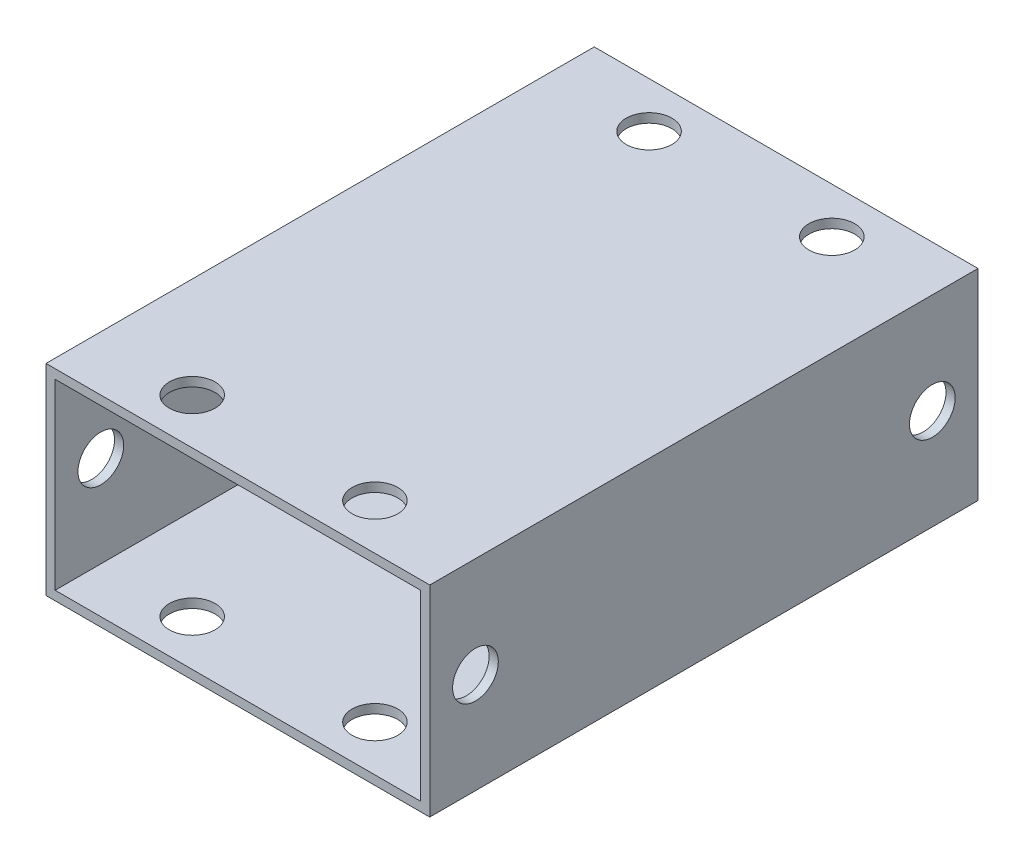
from build123d import *

# Parameters (mm, degrees)
BOSS_EXTRUDE1_DEPTH     = 60
SKETCH2_R               = 2.5
CUT_EXTRUDE1_DEPTH      = 2
SKETCH3_R               = 2.5
CUT_EXTRUDE2_DEPTH      = 42
CUT_EXTRUDE2_DEPTH_BACK = 2
SKETCH4_W               = 42
SKETCH4_H               = 60
SKETCH4_R               = 2.5
BOSS_EXTRUDE2_DEPTH     = 1


with BuildPart() as part:
    # Sketch1 → Boss-Extrude1 (new body)
    with BuildSketch(Plane.XY):
        Polygon((-20, -10), (-20, 10), (20, 10), (20, -10), (21, -10), (21, 11), (-21, 11), (-21, -10), align=None)
    extrude(amount=BOSS_EXTRUDE1_DEPTH)

    # Sketch2 → Cut-Extrude1 (cut, through all)
    with BuildSketch(Plane.XZ.offset(-10)):
        with Locations((-10, 5)):
            Circle(SKETCH2_R)
        with Locations((10, 5)):
            Circle(SKETCH2_R)
        with Locations((10, 55)):
            Circle(SKETCH2_R)
        with Locations((-10, 55)):
            Circle(SKETCH2_R)
    extrude(amount=-CUT_EXTRUDE1_DEPTH, mode=Mode.SUBTRACT)

    # Sketch3 → Cut-Extrude2 (cut, two sides)
    with BuildSketch(Plane.ZY.offset(-20)) as cut_extrude2_sk:
        with Locations((5, 0)):
            Circle(SKETCH3_R)
        with Locations((55, 0)):
            Circle(SKETCH3_R)
    extrude(amount=CUT_EXTRUDE2_DEPTH, mode=Mode.SUBTRACT)
    extrude(cut_extrude2_sk.sketch, amount=-CUT_EXTRUDE2_DEPTH_BACK, mode=Mode.SUBTRACT)

    # Sketch4 → Boss-Extrude2 (add)
    with BuildSketch(Plane.XZ.offset(10)):
        with Locations((0, 30)):
            Rectangle(SKETCH4_W, SKETCH4_H)
        with Locations((-10, 5)):
            Circle(SKETCH4_R, mode=Mode.SUBTRACT)
        with Locations((-10, 55)):
            Circle(SKETCH4_R, mode=Mode.SUBTRACT)
        with Locations((10, 55)):
            Circle(SKETCH4_R, mode=Mode.SUBTRACT)
        with Locations((10, 5)):
            Circle(SKETCH4_R, mode=Mode.SUBTRACT)
    extrude(amount=BOSS_EXTRUDE2_DEPTH)


solid = part.part
